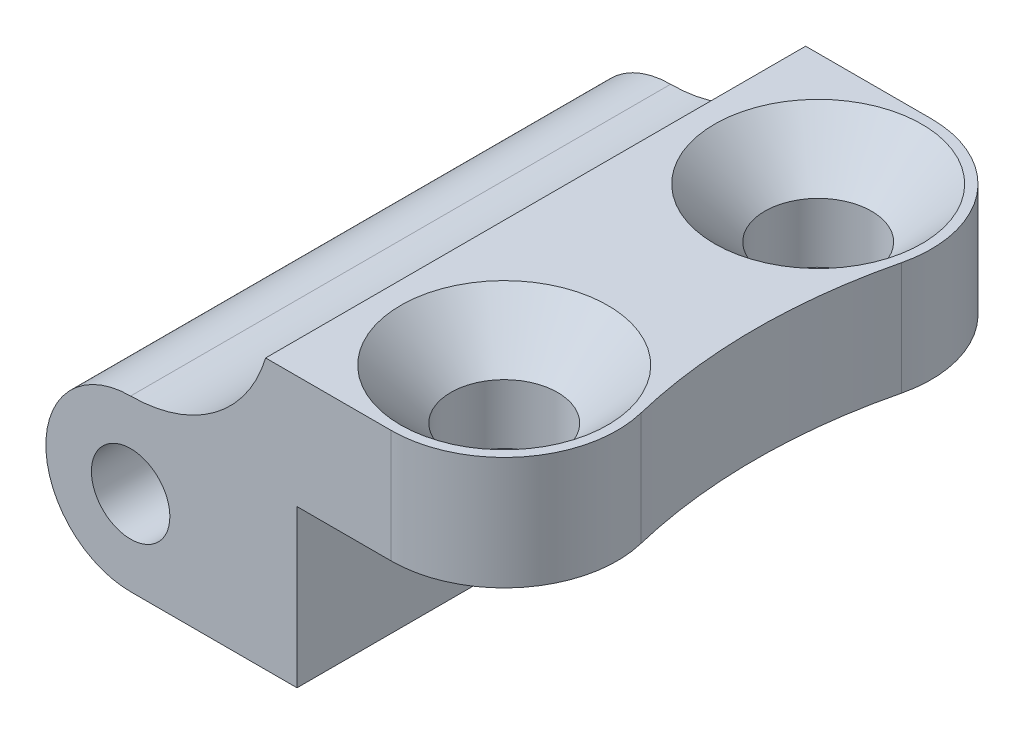
from build123d import *

# Parameters (mm, degrees)
SKETCH_1_R                = 1.25
EXTRUDE_1_DEPTH           = 17.2
CUT_EXTRUDE_1_DEPTH       = 9.6
HOLE_WIZARD_1_D           = 3.4
HOLE_WIZARD_1_DEPTH       = 3.5
HOLE_WIZARD_1_CSINK_D     = 6.6
HOLE_WIZARD_1_CSINK_ANGLE = 90
HOLE_WIZARD_1_TIP         = 1.021463052
EXTRUDE_3_DEPTH           = 4


with BuildPart() as part:
    # 草图1 → 凸台-拉伸1 (new body)
    with BuildSketch(Plane.XY):
        with BuildLine():
            Line((0, -2.7), (5.3, -2.7))
            Line((5.3, -2.7), (5.3, 2.3))
            Line((5.3, 2.3), (12.8, 2.3))
            Line((12.8, 2.3), (12.8, 5.9))
            Line((12.8, 5.9), (4.3, 5.9))
            ThreePointArc((4.3, 5.9), (2.680018657, 3.58778743), (0, 2.7))
            ThreePointArc((0, 2.7), (-2.7, 0), (0, -2.7))
        make_face()
        Circle(SKETCH_1_R, mode=Mode.SUBTRACT)
    extrude(amount=EXTRUDE_1_DEPTH)

    # 草图2 → 切除-拉伸1 (cut, through all)
    with BuildSketch(Plane(origin=(0, 5.9, 0), x_dir=(1, 0, 0), z_dir=(0, 1, 0))):
        with BuildLine():
            Line((12.8, -17.2), (12.8, 0))
            Line((12.8, 0), (8.3, 0))
            ThreePointArc((8.3, 0), (10.845584412, -1.054415588), (11.9, -3.6))
            ThreePointArc((11.9, -3.6), (11.874356619, -4.028922794), (11.797791798, -4.451735016))
            ThreePointArc((11.797791798, -4.451735016), (11.3, -8.6), (11.797791798, -12.748264984))
            ThreePointArc((11.797791798, -12.748264984), (11.874356619, -13.171077206), (11.9, -13.6))
            ThreePointArc((11.9, -13.6), (10.845584412, -16.145584412), (8.3, -17.2))
            Line((8.3, -17.2), (12.8, -17.2))
        make_face()
    extrude(amount=-CUT_EXTRUDE_1_DEPTH, mode=Mode.SUBTRACT)

    # 打孔尺寸(%根据)开槽半沉头木螺钉的类型1
    with Locations(Plane(origin=(8.3, 5.9, 3.6), x_dir=(1, 0, 0), z_dir=(0, 1, 0))):
        with Locations((0, 0), (0, -10)):
            CounterSinkHole(HOLE_WIZARD_1_D / 2, HOLE_WIZARD_1_CSINK_D / 2, depth=HOLE_WIZARD_1_DEPTH, counter_sink_angle=HOLE_WIZARD_1_CSINK_ANGLE)
            with Locations((0, 0, -(HOLE_WIZARD_1_DEPTH + HOLE_WIZARD_1_TIP / 2))):  # 118° drill point
                Cone(0, HOLE_WIZARD_1_D / 2, HOLE_WIZARD_1_TIP, mode=Mode.SUBTRACT)

    # 草图5 → 凸台-拉伸3 (add)
    with BuildSketch(Plane.XY.offset(7.4)):
        Polygon((5.3, 2.3), (5.3, -0.528427125), (8.128427125, 2.3), align=None)
    extrude(amount=EXTRUDE_3_DEPTH)


solid = part.part
